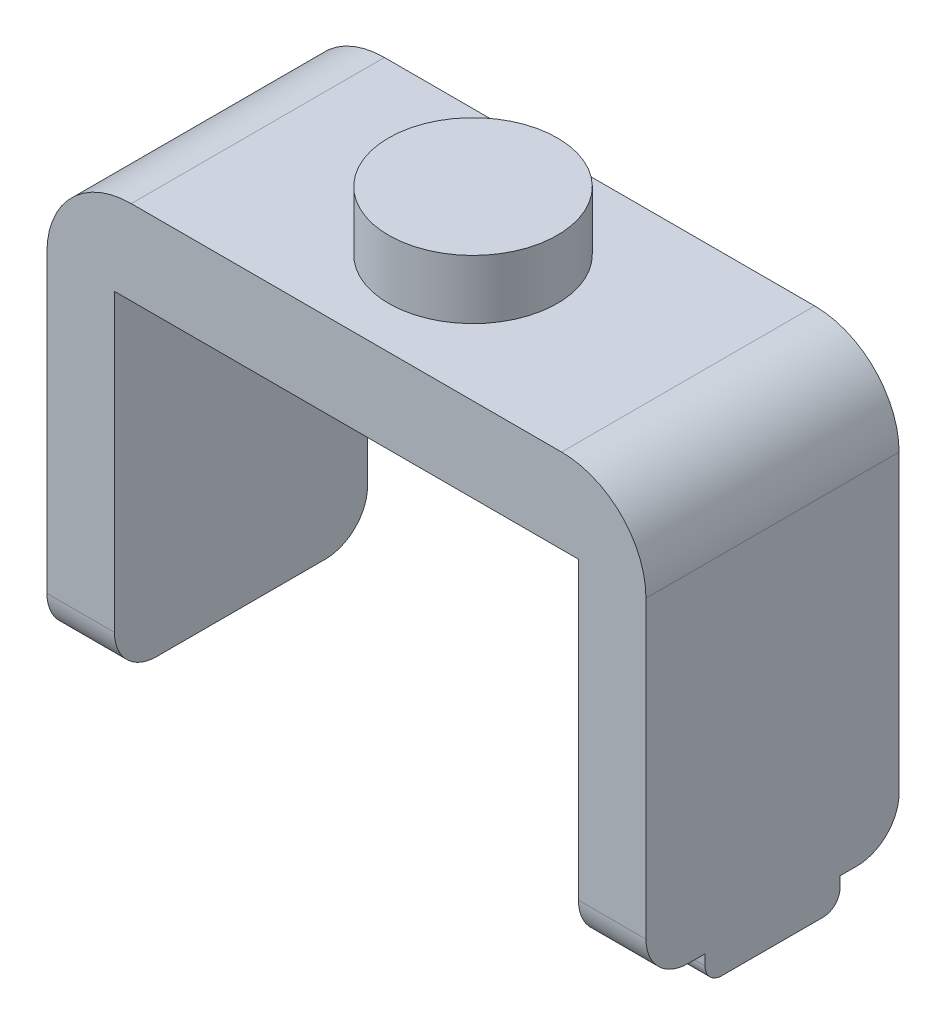
from build123d import *

# Parameters (mm, degrees)
BOSS_EXTRUDE1_DEPTH = 30
SKETCH2_R           = 10
BOSS_EXTRUDE2_DEPTH = 7
FILLET1_R           = 5
FILLET2_R           = 10
SKETCH3_W           = 8
SKETCH3_H           = 16
BOSS_EXTRUDE3_DEPTH = 3.25
FILLET3_R           = 2


with BuildPart() as part:
    # Sketch1 → Boss-Extrude1 (new body)
    with BuildSketch(Plane.XY):
        Polygon((-289.346773142, -20.703646913), (-289.346773142, 19.296353087), (-234.346773142, 19.296353087), (-234.346773142, -20.703646913), (-226.346773142, -20.703646913), (-226.346773142, 29.296353087), (-297.346773142, 29.296353087), (-297.346773142, -20.703646913), align=None)
    extrude(amount=-BOSS_EXTRUDE1_DEPTH)

    # Sketch2 → Boss-Extrude2 (add)
    with BuildSketch(Plane(origin=(0, 29.296353087, 0), x_dir=(1, 0, 0), z_dir=(0, 1, 0))):
        with Locations((-261.846773142, 15)):
            Circle(SKETCH2_R)
    extrude(amount=BOSS_EXTRUDE2_DEPTH)

    # Fillet1
    fillet1_edges = [part.edges().sort_by_distance(p)[0] for p in [
        (-293.346773142, -20.703646913, 0),
        (-293.346773142, -20.703646913, -30),
        (-230.346773142, -20.703646913, 0),
        (-230.346773142, -20.703646913, -30),
    ]]
    fillet(fillet1_edges, radius=FILLET1_R)

    # Fillet2
    fillet2_edges = [part.edges().sort_by_distance(p)[0] for p in [
        (-297.346773142, 29.296353087, -15),
        (-226.346773142, 29.296353087, -15),
    ]]
    fillet(fillet2_edges, radius=FILLET2_R)

    # Sketch3 → Boss-Extrude3 (add)
    with BuildSketch(Plane.XZ.offset(20.703646913)):
        with Locations((-230.346773142, -15)):
            Rectangle(SKETCH3_W, SKETCH3_H)
    extrude(amount=BOSS_EXTRUDE3_DEPTH)

    # Fillet3
    fillet3_edges = [part.edges().sort_by_distance(p)[0] for p in [
        (-230.346773142, -23.953646913, -7),
        (-230.346773142, -23.953646913, -23),
    ]]
    fillet(fillet3_edges, radius=FILLET3_R)


solid = part.part
